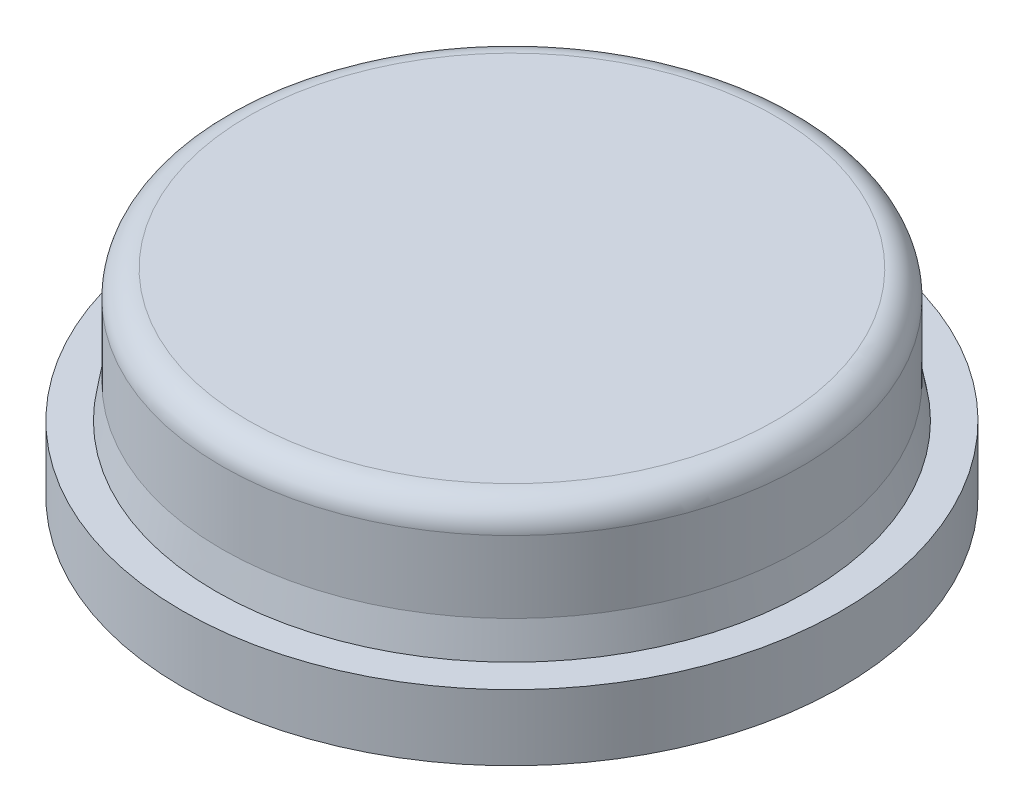
from build123d import *

# Parameters (mm, degrees)
SKETCH_2_R          = 5
EXTRUDE_1_DEPTH     = 1
SKETCH_3_R          = 4.4
EXTRUDE_2_DEPTH     = 2
FILLET_1_R          = 0.4
CHAMFER_1_SIZE      = 0.09
CHAMFER_1_SIZE2     = 0.510415364
SKETCH_4_R          = 1.65
CUT_EXTRUDE_1_DEPTH = 1.65


with BuildPart() as part:
    # 草图2 → 凸台-拉伸1 (new body)
    with BuildSketch(Plane(origin=(0, 0, 0), x_dir=(1, 0, 0), z_dir=(0, 1, 0))):
        Circle(SKETCH_2_R)
    extrude(amount=EXTRUDE_1_DEPTH)

    # 草图3 → 凸台-拉伸2 (add)
    with BuildSketch(Plane(origin=(0, 1, 0), x_dir=(1, 0, 0), z_dir=(0, 1, 0))):
        Circle(SKETCH_3_R)
    extrude(amount=EXTRUDE_2_DEPTH)

    # 圆角1
    fillet_1_edges = [part.edges().sort_by_distance(p)[0] for p in [
        (-4.4, 3, 0),
    ]]
    fillet(fillet_1_edges, radius=FILLET_1_R)

    # 倒角1
    chamfer_1_edges = [part.edges().sort_by_distance(p)[0] for p in [
        (-4.4, 1, 0),
    ]]
    chamfer_1_side = [part.faces().sort_by_distance(p)[0] for p in [
        (-4.858578644, 1, 0),
    ]]
    chamfer(chamfer_1_edges, length=CHAMFER_1_SIZE, length2=CHAMFER_1_SIZE2, reference=chamfer_1_side[0])

    # 草图4 → 切除-拉伸1 (cut)
    with BuildSketch(Plane.XZ):
        Circle(SKETCH_4_R)
    extrude(amount=-CUT_EXTRUDE_1_DEPTH, mode=Mode.SUBTRACT)


solid = part.part
